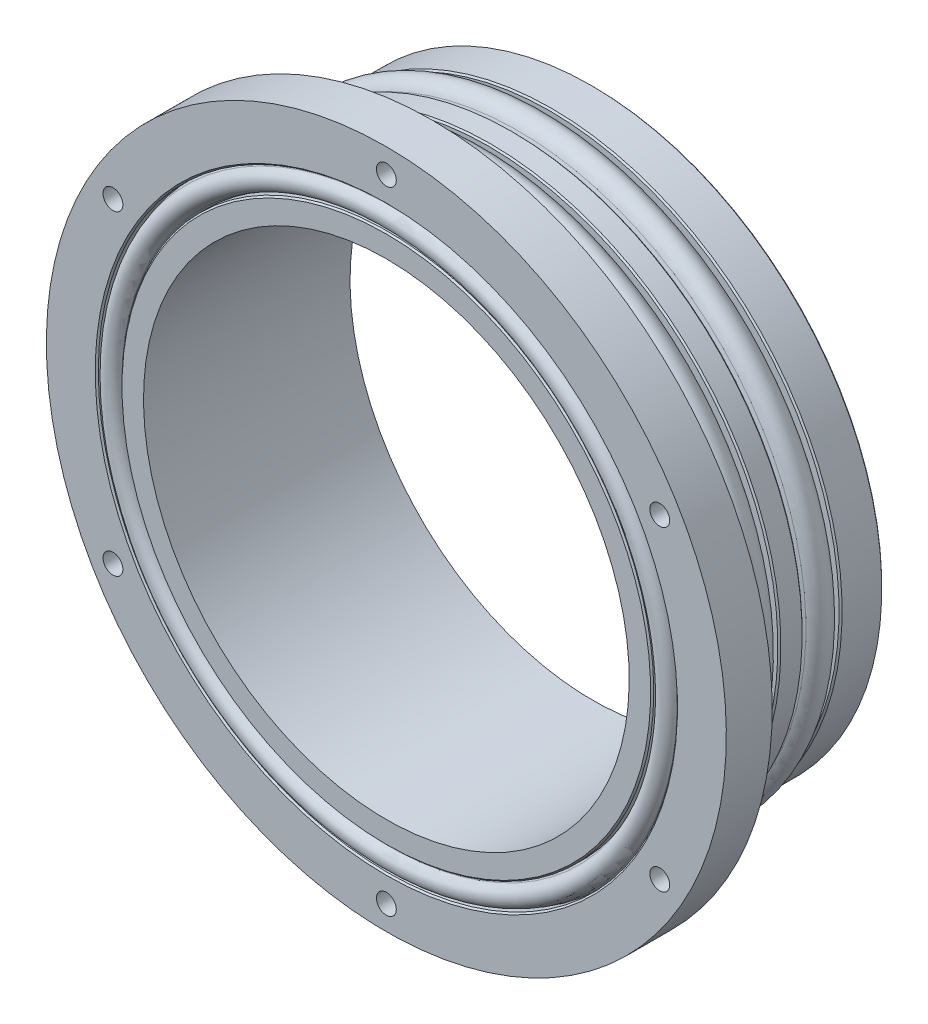
from build123d import *

# Parameters (mm, degrees)
SKETCH2_R          = 1.3
CUT_EXTRUDE1_DEPTH = 6
CHAMFER1_SIZE      = 0.2
SKETCH3_R          = 1.3
CUT_EXTRUDE2_DEPTH = 4


with BuildPart() as part:
    # Sketch1 → Revolve1 (revolve)
    with BuildSketch(Plane(origin=(0, 0, 0), x_dir=(0, 0, -1), z_dir=(1, 0, 0))):
        Polygon((0, 37.973), (-5.587, 37.973), (-5.587, 35.2806), (-10.413, 35.2806), (-10.413, 37.973), (-13.587, 37.973), (-13.587, 35.2806), (-18.413, 35.2806), (-18.413, 37.973), (-21, 37.973), (-21, 44.45), (-27, 44.45), (-27, 37.8587), (-24.9426, 37.8587), (-24.9426, 34.7599), (-27, 34.7599), (-27, 31.75), (0, 31.75), align=None)
    revolve(axis=Axis((0, 0, 0), (0, 0, 1)))

    # Sketch2 → Cut-Extrude1 (cut)
    with BuildSketch(Plane.XY.offset(27)):
        with Locations((0, 41.275)):
            Circle(SKETCH2_R)
        with Locations((35.745198541, 20.6375)):
            Circle(SKETCH2_R)
        with Locations((35.745198541, -20.6375)):
            Circle(SKETCH2_R)
        with Locations((0, -41.275)):
            Circle(SKETCH2_R)
        with Locations((-35.745198541, -20.6375)):
            Circle(SKETCH2_R)
        with Locations((-35.745198541, 20.6375)):
            Circle(SKETCH2_R)
    extrude(amount=-CUT_EXTRUDE1_DEPTH, mode=Mode.SUBTRACT)

    # Chamfer1
    chamfer1_edges = [part.edges().sort_by_distance(p)[0] for p in [
        (0, -34.7599, 27),
        (0, -37.8587, 27),
        (0, -37.973, 18.413),
        (0, -37.973, 13.587),
        (0, -37.973, 10.413),
        (0, -37.973, 5.587),
        (0, -37.973, 0),
    ]]
    chamfer(chamfer1_edges, length=CHAMFER1_SIZE)

    # Sketch3 → Cut-Extrude2 (cut)
    with BuildSketch(Plane(origin=(0, 0, 0), x_dir=(-1, 0, 0), z_dir=(0, 0, -1))):
        with Locations((-34.29, 0)):
            Circle(SKETCH3_R)
        with Locations((0, 34.29)):
            Circle(SKETCH3_R)
        with Locations((34.29, 0)):
            Circle(SKETCH3_R)
        with Locations((0, -34.29)):
            Circle(SKETCH3_R)
    extrude(amount=-CUT_EXTRUDE2_DEPTH, mode=Mode.SUBTRACT)

    # Sketch4 → Revolve2 (revolve)
    with BuildSketch(Plane(origin=(0, 0, 0), x_dir=(0, 0, -1), z_dir=(1, 0, 0))):
        with BuildLine():
            Line((-13.587, 36.0426), (-14.2347, 37.626020071))
            ThreePointArc((-14.2347, 37.626020071), (-16, 38.8112), (-17.7653, 37.626020071))
            Line((-17.7653, 37.626020071), (-18.413, 36.0426))
            Line((-18.413, 36.0426), (-18.413, 35.2806))
            Line((-18.413, 35.2806), (-13.587, 35.2806))
            Line((-13.587, 35.2806), (-13.587, 36.0426))
        make_face()
        with BuildLine():
            Line((-5.587, 36.0426), (-6.2347, 37.626020071))
            ThreePointArc((-6.2347, 37.626020071), (-8, 38.8112), (-9.7653, 37.626020071))
            Line((-9.7653, 37.626020071), (-10.413, 36.0426))
            Line((-10.413, 36.0426), (-10.413, 35.2806))
            Line((-10.413, 35.2806), (-5.587, 35.2806))
            Line((-5.587, 35.2806), (-5.587, 36.0426))
        make_face()
        with BuildLine():
            Line((-24.9426, 37.89011096), (-25.7046, 37.89011096))
            Line((-25.7046, 37.89011096), (-26.594145523, 37.6149823))
            ThreePointArc((-26.594145523, 37.6149823), (-27.5588, 36.3068823), (-26.594145523, 34.9987823))
            Line((-26.594145523, 34.9987823), (-25.7046, 34.72365364))
            Line((-25.7046, 34.72365364), (-24.9426, 34.72365364))
            Line((-24.9426, 34.72365364), (-24.9426, 37.89011096))
        make_face()
    revolve(axis=Axis((0, 0, 0), (0, 0, 1)))


solid = part.part
